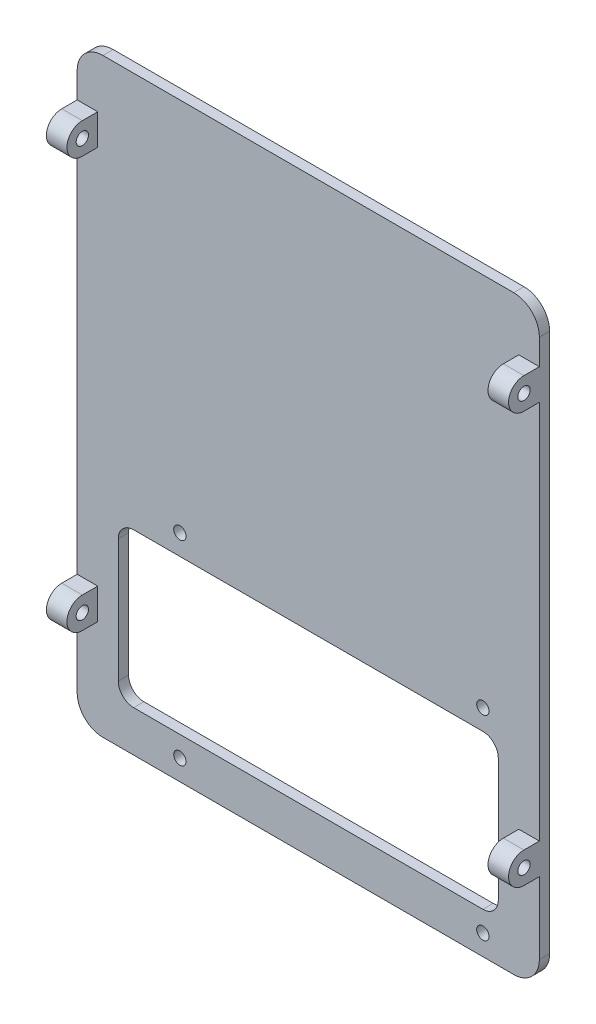
from build123d import *

# Parameters (mm, degrees)
SKETCH1_R                        = 1.524
SCREW_HOLES_DEPTH                = 5.08
SCREW_HOLES_2_DEPTH              = 5.08
SKETCH2_W                        = 2.54
SKETCH2_H                        = 146.05
MAIN_EXTRUDE_DEPTH               = 114.3
FILLET1_R                        = 6.35
SKETCH3_R                        = 1.524
COMPONENT_MOUNT_HOLES_DEPTH      = 8.62
COMPONENT_MOUNT_HOLES_DEPTH_BACK = 3.54
SKETCH4_W                        = 93.98
SKETCH4_H                        = 38.1
WEIGHT_REDUCTION_DEPTH           = 8.62
WEIGHT_REDUCTION_DEPTH_BACK      = 3.54
FILLET2_R                        = 3.81


with BuildPart() as part:
    # Sketch1 → Screw holes (new body)
    with BuildSketch(Plane(origin=(0, 0, 0), x_dir=(0, 0, -1), z_dir=(1, 0, 0))):
        with BuildLine():
            Line((0, 46.99), (3.81, 46.99))
            Line((3.81, 46.99), (3.81, 54.61))
            Line((3.81, 54.61), (0, 54.61))
            ThreePointArc((0, 54.61), (-3.81, 50.8), (0, 46.99))
        make_face()
        with Locations((0, 50.8)):
            Circle(SKETCH1_R, mode=Mode.SUBTRACT)
    screw_holes = extrude(amount=SCREW_HOLES_DEPTH)



with BuildPart() as body_2:
    # Sketch1 → Screw holes 2 (new body)
    with BuildSketch(Plane(origin=(0, 0, 0), x_dir=(0, 0, -1), z_dir=(1, 0, 0))):
        with BuildLine():
            Line((3.81, -54.61), (0, -54.61))
            ThreePointArc((0, -54.61), (-3.81, -50.8), (0, -46.99))
            Line((0, -46.99), (3.81, -46.99))
            Line((3.81, -46.99), (3.81, -54.61))
        make_face()
        with Locations((0, -50.8)):
            Circle(SKETCH1_R, mode=Mode.SUBTRACT)
    screw_holes_2 = extrude(amount=SCREW_HOLES_2_DEPTH)


with BuildPart() as part_1:
    add(part.part)

    add(body_2.part)  # Main extrude merges body 2
    # Sketch2 → Main extrude (add)
    with BuildSketch(Plane.ZY):
        with Locations((-5.08, -5.715)):
            Rectangle(SKETCH2_W, SKETCH2_H)
    extrude(amount=-MAIN_EXTRUDE_DEPTH)

    # Screw holes 2 2: Screw holes, Screw holes 2 across plane
    add(screw_holes.mirror(Plane.ZY.offset(-57.15)))
    add(screw_holes_2.mirror(Plane.ZY.offset(-57.15)))

    # Fillet1
    fillet1_edges = [part_1.edges().sort_by_distance(p)[0] for p in [
        (114.3, -78.74, -5.08),
        (114.3, 67.31, -5.08),
        (0, 67.31, -5.08),
        (0, -78.74, -5.08),
    ]]
    fillet(fillet1_edges, radius=FILLET1_R)

    # Sketch3 → Component mount holes (cut, two sides)
    with BuildSketch(Plane.XY.offset(-3.81)) as component_mount_holes_sk:
        with Locations((25.4, -25.4)):
            Circle(SKETCH3_R)
        with Locations((100.33, -25.4)):
            Circle(SKETCH3_R)
        with Locations((100.33, -73.66)):
            Circle(SKETCH3_R)
        with Locations((25.4, -73.66)):
            Circle(SKETCH3_R)
    extrude(amount=COMPONENT_MOUNT_HOLES_DEPTH, mode=Mode.SUBTRACT)
    extrude(component_mount_holes_sk.sketch, amount=-COMPONENT_MOUNT_HOLES_DEPTH_BACK, mode=Mode.SUBTRACT)

    # Sketch4 → Weight reduction (cut, two sides)
    with BuildSketch(Plane.XY.offset(-3.81)) as weight_reduction_sk:
        with Locations((57.15, -49.53)):
            Rectangle(SKETCH4_W, SKETCH4_H)
    extrude(amount=WEIGHT_REDUCTION_DEPTH, mode=Mode.SUBTRACT)
    extrude(weight_reduction_sk.sketch, amount=-WEIGHT_REDUCTION_DEPTH_BACK, mode=Mode.SUBTRACT)

    # Fillet2
    fillet2_edges = [part_1.edges().sort_by_distance(p)[0] for p in [
        (10.16, -68.58, -5.08),
        (10.16, -30.48, -5.08),
        (104.14, -30.48, -5.08),
        (104.14, -68.58, -5.08),
    ]]
    fillet(fillet2_edges, radius=FILLET2_R)


solid = part_1.part
